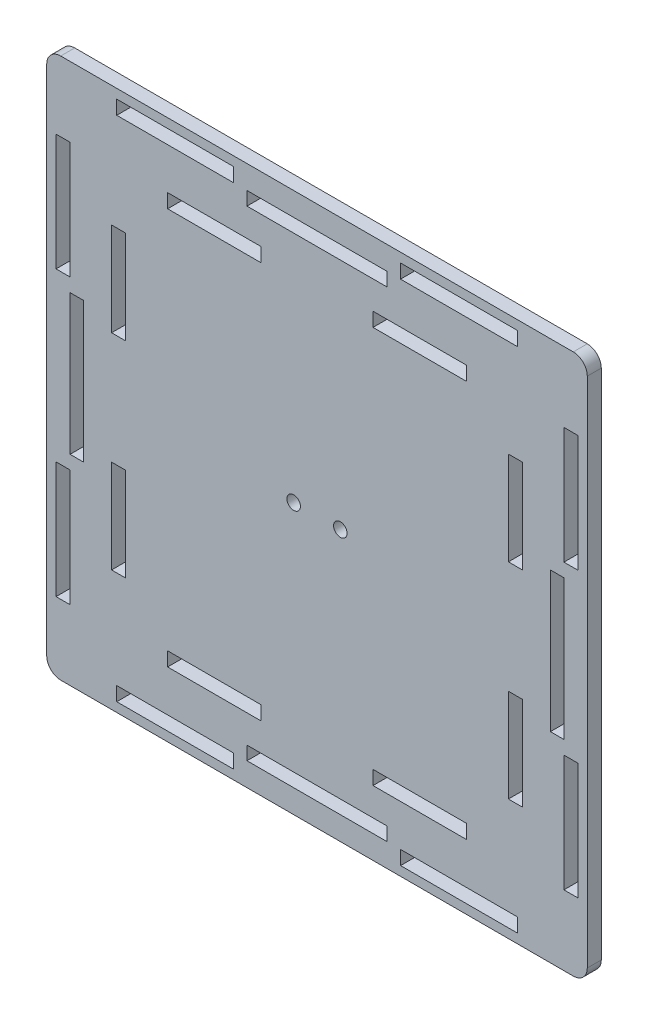
from build123d import *

# Parameters (mm, degrees)
SKETCH_1_R      = 1.45
SKETCH_1_W      = 25
SKETCH_1_H      = 3
SKETCH_1_W_2    = 3
SKETCH_1_H_2    = 25
SKETCH_1_W_3    = 20
SKETCH_1_H_3    = 20
SKETCH_1_W_4    = 30
SKETCH_1_H_4    = 2.9
SKETCH_1_W_5    = 2.9
SKETCH_1_H_5    = 30
EXTRUDE_2_DEPTH = 3


with BuildPart() as part:
    # 草图1 → 凸台-拉伸2 (new body)
    with BuildSketch(Plane.XY):
        with BuildLine():
            Line((104.9, 107.9), (-4.9, 107.9))
            ThreePointArc((-4.9, 107.9), (-7.021320344, 107.021320344), (-7.9, 104.9))
            Line((-7.9, 104.9), (-7.9, -4.9))
            ThreePointArc((-7.9, -4.9), (-7.021320344, -7.021320344), (-4.9, -7.9))
            Line((-4.9, -7.9), (104.9, -7.9))
            ThreePointArc((104.9, -7.9), (107.021320344, -7.021320344), (107.9, -4.9))
            Line((107.9, -4.9), (107.9, 104.9))
            ThreePointArc((107.9, 104.9), (107.021320344, 107.021320344), (104.9, 107.9))
        make_face()
        with Locations((45, 50)):
            Circle(SKETCH_1_R, mode=Mode.SUBTRACT)
        with Locations((55, 50)):
            Circle(SKETCH_1_R, mode=Mode.SUBTRACT)
        with Locations((19.6, -4.4)):
            Rectangle(SKETCH_1_W, SKETCH_1_H, mode=Mode.SUBTRACT)
        with Locations((-4.4, 19.6)):
            Rectangle(SKETCH_1_W_2, SKETCH_1_H_2, mode=Mode.SUBTRACT)
        with Locations((28, 7.5)):
            Rectangle(SKETCH_1_W_3, SKETCH_1_H, mode=Mode.SUBTRACT)
        with Locations((7.5, 28)):
            Rectangle(SKETCH_1_W_2, SKETCH_1_H_3, mode=Mode.SUBTRACT)
        with Locations((50, -1.45)):
            Rectangle(SKETCH_1_W_4, SKETCH_1_H_4, mode=Mode.SUBTRACT)
        with Locations((72, 7.5)):
            Rectangle(SKETCH_1_W_3, SKETCH_1_H, mode=Mode.SUBTRACT)
        with Locations((80.4, -4.4)):
            Rectangle(SKETCH_1_W, SKETCH_1_H, mode=Mode.SUBTRACT)
        with Locations((104.4, 19.6)):
            Rectangle(SKETCH_1_W_2, SKETCH_1_H_2, mode=Mode.SUBTRACT)
        with Locations((92.5, 28)):
            Rectangle(SKETCH_1_W_2, SKETCH_1_H_3, mode=Mode.SUBTRACT)
        with Locations((-1.45, 50)):
            Rectangle(SKETCH_1_W_5, SKETCH_1_H_5, mode=Mode.SUBTRACT)
        with Locations((7.5, 72)):
            Rectangle(SKETCH_1_W_2, SKETCH_1_H_3, mode=Mode.SUBTRACT)
        with Locations((-4.4, 80.4)):
            Rectangle(SKETCH_1_W_2, SKETCH_1_H_2, mode=Mode.SUBTRACT)
        with Locations((19.6, 104.4)):
            Rectangle(SKETCH_1_W, SKETCH_1_H, mode=Mode.SUBTRACT)
        with Locations((28, 92.5)):
            Rectangle(SKETCH_1_W_3, SKETCH_1_H, mode=Mode.SUBTRACT)
        with Locations((80.4, 104.4)):
            Rectangle(SKETCH_1_W, SKETCH_1_H, mode=Mode.SUBTRACT)
        with Locations((101.45, 50)):
            Rectangle(SKETCH_1_W_5, SKETCH_1_H_5, mode=Mode.SUBTRACT)
        with Locations((92.5, 72)):
            Rectangle(SKETCH_1_W_2, SKETCH_1_H_3, mode=Mode.SUBTRACT)
        with Locations((72, 92.5)):
            Rectangle(SKETCH_1_W_3, SKETCH_1_H, mode=Mode.SUBTRACT)
        with Locations((50, 101.45)):
            Rectangle(SKETCH_1_W_4, SKETCH_1_H_4, mode=Mode.SUBTRACT)
        with Locations((104.4, 80.4)):
            Rectangle(SKETCH_1_W_2, SKETCH_1_H_2, mode=Mode.SUBTRACT)
    extrude(amount=EXTRUDE_2_DEPTH)


solid = part.part
